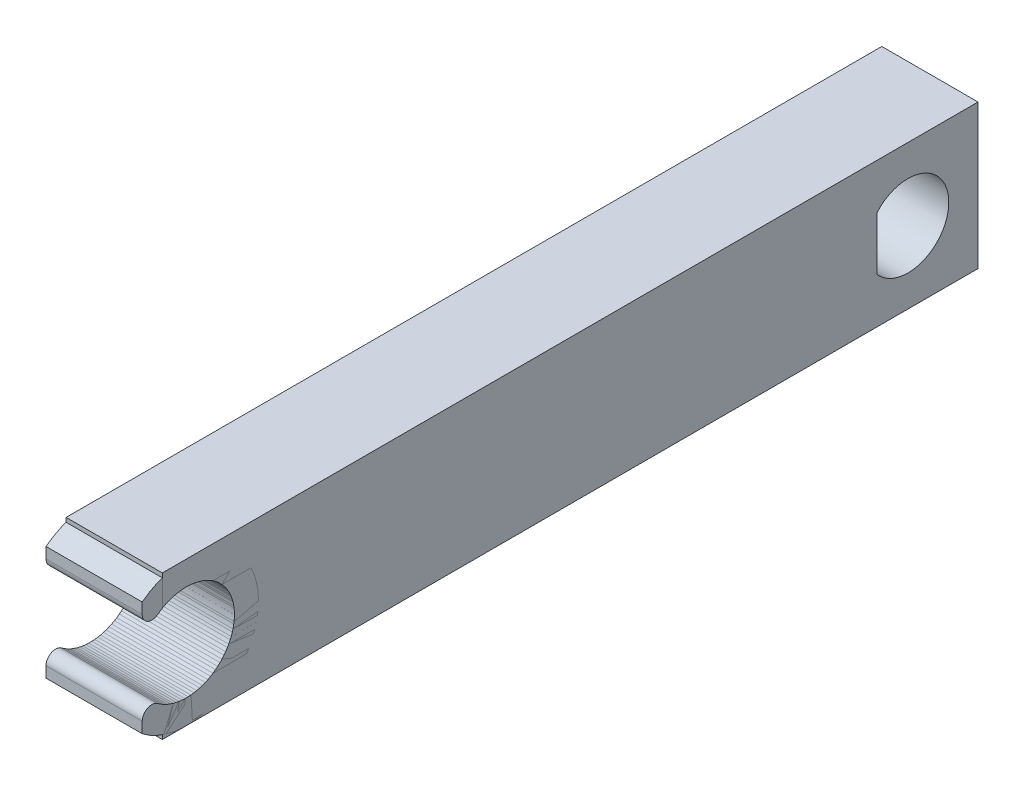
from build123d import *

# Parameters (mm, degrees)
SKETCH_1_W          = 8
SKETCH_1_H          = 12
EXTRUDE_1_DEPTH     = 82
SKETCH_2_R          = 6
SKETCH_2_R_2        = 4
EXTRUDE_2_DEPTH     = 8
CUT_EXTRUDE_1_DEPTH = 44
CUT_EXTRUDE_2_DEPTH = 8
FILLET_2_R          = 0.8
SKETCH_5_W          = 14.17198175
SKETCH_5_H          = 12
CUT_EXTRUDE_3_DEPTH = 10


with BuildPart() as part:
    # 草图1 → 凸台-拉伸1 (new body)
    with BuildSketch(Plane.XY):
        with Locations((-6.4060213, -18.331726276)):
            Rectangle(SKETCH_1_W, SKETCH_1_H)
    extrude(amount=EXTRUDE_1_DEPTH)

    # 草图2<3> → 切除-拉伸2 (cut)
    with BuildSketch(Plane.ZY.offset(10.4060213)):
        with BuildLine():
            Line((82, -18.331726276), (82, -14.86762466))
            ThreePointArc((82, -14.86762466), (76, -18.331726276), (82, -21.795827891))
            Line((82, -21.795827891), (82, -18.331726276))
        make_face()
    extrude(amount=-CUT_EXTRUDE_2_DEPTH, mode=Mode.SUBTRACT)

    # 草图5 → 切除-拉伸3 (cut)
    with BuildSketch(Plane.ZY.offset(10.4060213)):
        with Locations((7.085990875, -18.331726276)):
            Rectangle(SKETCH_5_W, SKETCH_5_H)
        with BuildLine():
            ThreePointArc((22.555938676, -16.089589464), (18.802125111, -15.149730715), (16.6, -18.331726276))
            ThreePointArc((16.6, -18.331726276), (18.802125111, -21.513721837), (22.555938676, -20.573863088))
            Line((22.555938676, -20.573863088), (22.555938676, -16.089589464))
        make_face()
    extrude(amount=-CUT_EXTRUDE_3_DEPTH, mode=Mode.SUBTRACT)


with BuildPart() as body_2:
    # 草图2 → 凸台-拉伸2 (new body)
    with BuildSketch(Plane.ZY.offset(10.4060213)):
        with Locations((80, -18.331726276)):
            Circle(SKETCH_2_R)
        with Locations((80, -18.331726276)):
            Circle(SKETCH_2_R_2, mode=Mode.SUBTRACT)
    extrude(amount=-EXTRUDE_2_DEPTH)

    # 草图3 → 切除-拉伸1 (cut)
    with BuildSketch(Plane.ZY.offset(10.4060213)):
        Polygon((83.67416335, -12.331726276), (83.67416335, -43.507085013), (128.40681493, -43.507085013), (128.40681493, -12.331726276), (128.40681493, -1.616938917), (83.67416335, -1.616938917), align=None)
    extrude(amount=-CUT_EXTRUDE_1_DEPTH, mode=Mode.SUBTRACT)

    # 圆角2
    fillet_2_edges = [body_2.edges().sort_by_distance(p)[0] for p in [
        (-6.4060213, -19.913030697, 83.67416335),
        (-6.4060213, -16.750421854, 83.67416335),
    ]]
    fillet(fillet_2_edges, radius=FILLET_2_R)


solid = Compound([part.part, body_2.part])
